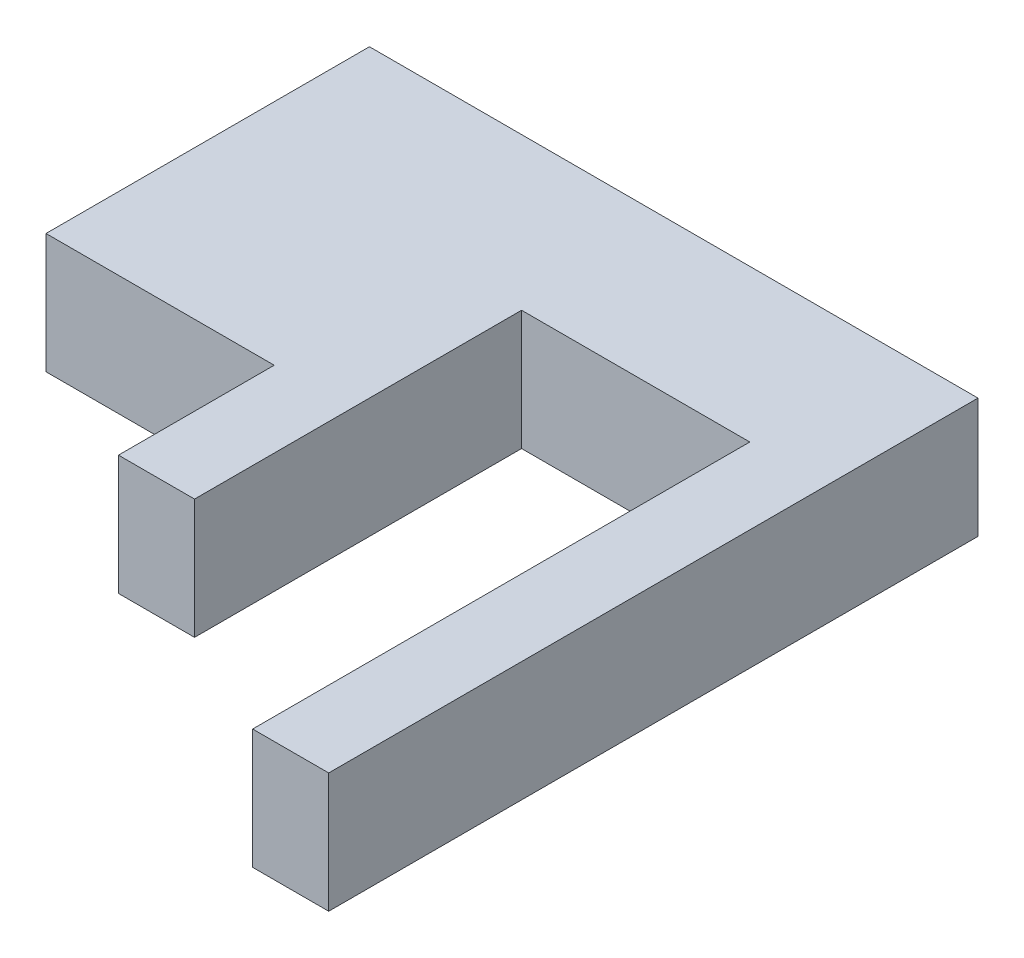
from build123d import *

# Parameters (mm, degrees)
BOSS_EXTRUDE1_DEPTH = 10


with BuildPart() as part:
    # Sketch1 → Boss-Extrude1 (new body)
    with BuildSketch(Plane(origin=(0, 0, 0), x_dir=(1, 0, 0), z_dir=(0, 1, 0))):
        Polygon((-111.210993036, 33.624609368), (-85.810993036, 33.624609368), (-60.410993036, 33.624609368), (-60.410993036, 31.886854206), (-60.410993036, -20.575390632), (-66.760993036, -20.575390632), (-66.760993036, 20.924609368), (-85.810993036, 20.924609368), (-85.810993036, -6.375390632), (-92.160993036, -6.375390632), (-92.160993036, 6.624609368), (-111.210993036, 6.624609368), align=None)
    extrude(amount=BOSS_EXTRUDE1_DEPTH)


solid = part.part
